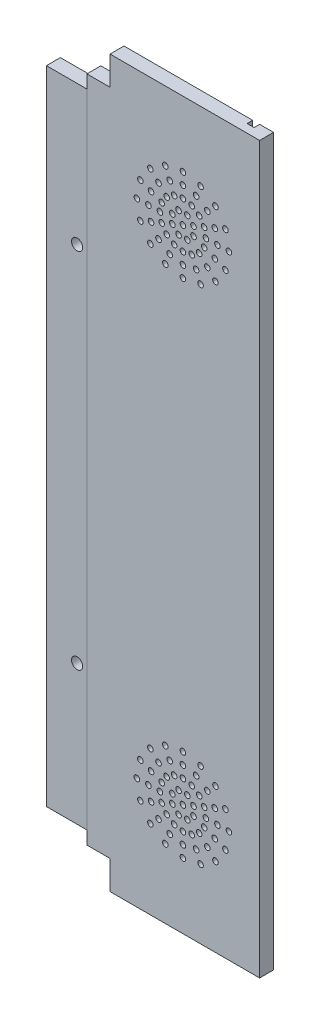
from build123d import *

# Parameters (mm, degrees)
CROQUIS1_W              = 67.920898
CROQUIS1_H              = 260
SALIENTE_EXTRUIR1_DEPTH = 5
CROQUIS3_W              = 2.5
CROQUIS3_H              = 260
CORTAR_EXTRUIR2_DEPTH   = 2
CORTAR_EXTRUIR3_REACH   = 7
CROQUIS5_R              = 1
CORTAR_EXTRUIR4_DEPTH   = 5
CROQUIS6_W              = 14.5
CROQUIS6_H              = 230
CROQUIS6_R              = 2
SALIENTE_EXTRUIR2_DEPTH = 5


with BuildPart() as part:
    # Croquis1 → Saliente-Extruir1 (new body)
    with BuildSketch(Plane.XY):
        with Locations((-1.84343465, -4.813673922)):
            Rectangle(CROQUIS1_W, CROQUIS1_H)
    extrude(amount=SALIENTE_EXTRUIR1_DEPTH)

    # Croquis3 → Cortar-Extruir2 (cut)
    with BuildSketch(Plane(origin=(0, 0, 0), x_dir=(-1, 0, 0), z_dir=(0, 0, -1))):
        with Locations((-25.86701435, -4.813673922)):
            Rectangle(CROQUIS3_W, CROQUIS3_H)
    extrude(amount=-CORTAR_EXTRUIR2_DEPTH, mode=Mode.SUBTRACT)

    # Croquis4 → Cortar-Extruir3 (cut, up to next)
    with BuildSketch(Plane(origin=(0, 0, 0), x_dir=(-1, 0, 0), z_dir=(0, 0, -1)), mode=Mode.PRIVATE) as cortar_extruir3_sk1:
        Polygon((35.80388365, 125.186326078), (29.80388365, 125.186326078), (21.50388365, 125.186326078), (21.50388365, 114.886326078), (29.80388365, 114.886326078), (29.80388365, -124.513673922), (21.50388365, -124.513673922), (21.50388365, -134.813673922), (29.80388365, -134.813673922), (35.80388365, -134.813673922), align=None)
    cortar_extruir3_tool1 = extrude(cortar_extruir3_sk1.sketch, amount=-CORTAR_EXTRUIR3_REACH, mode=Mode.PRIVATE) & part.part
    add(cortar_extruir3_tool1.solids().sort_by_distance((-32.097632, -4.813674, 0))[0], mode=Mode.SUBTRACT)

    # Croquis5 → Cortar-Extruir4 (cut)
    with BuildSketch(Plane(origin=(0, 0, 0), x_dir=(-1, 0, 0), z_dir=(0, 0, -1))):
        with Locations((-4.61701435, 101.686326078)):
            Circle(CROQUIS5_R)
        with Locations((-4.61701435, 97.556326078)):
            Circle(CROQUIS5_R)
        with Locations((-4.61701435, 93.426326078)):
            Circle(CROQUIS5_R)
        with Locations((-4.61701435, 85.166326078)):
            Circle(CROQUIS5_R)
        with Locations((-3.044185443, 88.983470956)):
            Circle(CROQUIS5_R)
        with Locations((-1.463702867, 92.799093426)):
            Circle(CROQUIS5_R)
        with Locations((0.116779709, 96.614715895)):
            Circle(CROQUIS5_R)
        with Locations((1.697262284, 100.430338364)):
            Circle(CROQUIS5_R)
        with Locations((1.209545527, 91.012885955)):
            Circle(CROQUIS5_R)
        with Locations((4.129896534, 93.933236961)):
            Circle(CROQUIS5_R)
        with Locations((7.05024754, 96.853587967)):
            Circle(CROQUIS5_R)
        with Locations((-0.819869471, 86.759154985)):
            Circle(CROQUIS5_R)
        with Locations((2.995752998, 88.33963756)):
            Circle(CROQUIS5_R)
        with Locations((6.811375467, 89.920120136)):
            Circle(CROQUIS5_R)
        with Locations((10.626997937, 91.500602712)):
            Circle(CROQUIS5_R)
        with Locations((3.62298565, 85.186326078)):
            Circle(CROQUIS5_R)
        with Locations((7.75298565, 85.186326078)):
            Circle(CROQUIS5_R)
        with Locations((11.88298565, 85.186326078)):
            Circle(CROQUIS5_R)
        with Locations((-0.819869471, 83.613497171)):
            Circle(CROQUIS5_R)
        with Locations((2.995752998, 82.033014595)):
            Circle(CROQUIS5_R)
        with Locations((6.811375467, 80.452532019)):
            Circle(CROQUIS5_R)
        with Locations((10.626997937, 78.872049444)):
            Circle(CROQUIS5_R)
        with Locations((1.209545527, 79.359766201)):
            Circle(CROQUIS5_R)
        with Locations((4.129896534, 76.439415194)):
            Circle(CROQUIS5_R)
        with Locations((7.05024754, 73.519064188)):
            Circle(CROQUIS5_R)
        with Locations((-3.044185443, 81.389181199)):
            Circle(CROQUIS5_R)
        with Locations((-1.463702867, 77.57355873)):
            Circle(CROQUIS5_R)
        with Locations((0.116779709, 73.75793626)):
            Circle(CROQUIS5_R)
        with Locations((1.697262284, 69.942313791)):
            Circle(CROQUIS5_R)
        with Locations((-4.61701435, 76.946326078)):
            Circle(CROQUIS5_R)
        with Locations((-4.61701435, 72.816326078)):
            Circle(CROQUIS5_R)
        with Locations((-4.61701435, 68.686326078)):
            Circle(CROQUIS5_R)
        with Locations((-6.189843257, 81.389181199)):
            Circle(CROQUIS5_R)
        with Locations((-7.770325832, 77.57355873)):
            Circle(CROQUIS5_R)
        with Locations((-9.350808408, 73.75793626)):
            Circle(CROQUIS5_R)
        with Locations((-10.931290984, 69.942313791)):
            Circle(CROQUIS5_R)
        with Locations((-10.443574227, 79.359766201)):
            Circle(CROQUIS5_R)
        with Locations((-13.363925233, 76.439415194)):
            Circle(CROQUIS5_R)
        with Locations((-16.284276239, 73.519064188)):
            Circle(CROQUIS5_R)
        with Locations((-8.414159228, 83.613497171)):
            Circle(CROQUIS5_R)
        with Locations((-12.229781698, 82.033014595)):
            Circle(CROQUIS5_R)
        with Locations((-16.045404167, 80.452532019)):
            Circle(CROQUIS5_R)
        with Locations((-19.861026636, 78.872049444)):
            Circle(CROQUIS5_R)
        with Locations((-12.85701435, 85.186326078)):
            Circle(CROQUIS5_R)
        with Locations((-16.98701435, 85.186326078)):
            Circle(CROQUIS5_R)
        with Locations((-21.11701435, 85.186326078)):
            Circle(CROQUIS5_R)
        with Locations((-8.414159228, 86.759154985)):
            Circle(CROQUIS5_R)
        with Locations((-12.229781698, 88.33963756)):
            Circle(CROQUIS5_R)
        with Locations((-16.045404167, 89.920120136)):
            Circle(CROQUIS5_R)
        with Locations((-19.861026636, 91.500602712)):
            Circle(CROQUIS5_R)
        with Locations((-10.443574227, 91.012885955)):
            Circle(CROQUIS5_R)
        with Locations((-13.363925233, 93.933236961)):
            Circle(CROQUIS5_R)
        with Locations((-16.284276239, 96.853587967)):
            Circle(CROQUIS5_R)
        with Locations((-6.189843257, 88.983470956)):
            Circle(CROQUIS5_R)
        with Locations((-7.770325832, 92.799093426)):
            Circle(CROQUIS5_R)
        with Locations((-9.350808408, 96.614715895)):
            Circle(CROQUIS5_R)
        with Locations((-10.931290984, 100.430338364)):
            Circle(CROQUIS5_R)
        with Locations((-10.931290984, -110.057686209)):
            Circle(CROQUIS5_R)
        with Locations((-9.350808408, -106.24206374)):
            Circle(CROQUIS5_R)
        with Locations((-7.770325832, -102.42644127)):
            Circle(CROQUIS5_R)
        with Locations((-6.189843257, -98.610818801)):
            Circle(CROQUIS5_R)
        with Locations((-16.284276239, -106.480935812)):
            Circle(CROQUIS5_R)
        with Locations((-13.363925233, -103.560584806)):
            Circle(CROQUIS5_R)
        with Locations((-10.443574227, -100.640233799)):
            Circle(CROQUIS5_R)
        with Locations((-19.861026636, -101.127950556)):
            Circle(CROQUIS5_R)
        with Locations((-16.045404167, -99.547467981)):
            Circle(CROQUIS5_R)
        with Locations((-12.229781698, -97.966985405)):
            Circle(CROQUIS5_R)
        with Locations((-8.414159228, -96.386502829)):
            Circle(CROQUIS5_R)
        with Locations((-21.11701435, -94.813673922)):
            Circle(CROQUIS5_R)
        with Locations((-16.98701435, -94.813673922)):
            Circle(CROQUIS5_R)
        with Locations((-12.85701435, -94.813673922)):
            Circle(CROQUIS5_R)
        with Locations((-19.861026636, -88.499397288)):
            Circle(CROQUIS5_R)
        with Locations((-16.045404167, -90.079879864)):
            Circle(CROQUIS5_R)
        with Locations((-12.229781698, -91.66036244)):
            Circle(CROQUIS5_R)
        with Locations((-8.414159228, -93.240845015)):
            Circle(CROQUIS5_R)
        with Locations((-16.284276239, -83.146412033)):
            Circle(CROQUIS5_R)
        with Locations((-13.363925233, -86.066763039)):
            Circle(CROQUIS5_R)
        with Locations((-10.443574227, -88.987114045)):
            Circle(CROQUIS5_R)
        with Locations((-10.931290984, -79.569661636)):
            Circle(CROQUIS5_R)
        with Locations((-9.350808408, -83.385284105)):
            Circle(CROQUIS5_R)
        with Locations((-7.770325832, -87.200906574)):
            Circle(CROQUIS5_R)
        with Locations((-6.189843257, -91.016529044)):
            Circle(CROQUIS5_R)
        with Locations((-4.61701435, -78.313673922)):
            Circle(CROQUIS5_R)
        with Locations((-4.61701435, -82.443673922)):
            Circle(CROQUIS5_R)
        with Locations((-4.61701435, -86.573673922)):
            Circle(CROQUIS5_R)
        with Locations((1.697262284, -79.569661636)):
            Circle(CROQUIS5_R)
        with Locations((0.116779709, -83.385284105)):
            Circle(CROQUIS5_R)
        with Locations((-1.463702867, -87.200906574)):
            Circle(CROQUIS5_R)
        with Locations((-3.044185443, -91.016529044)):
            Circle(CROQUIS5_R)
        with Locations((7.05024754, -83.146412033)):
            Circle(CROQUIS5_R)
        with Locations((4.129896534, -86.066763039)):
            Circle(CROQUIS5_R)
        with Locations((1.209545527, -88.987114045)):
            Circle(CROQUIS5_R)
        with Locations((10.626997937, -88.499397288)):
            Circle(CROQUIS5_R)
        with Locations((6.811375467, -90.079879864)):
            Circle(CROQUIS5_R)
        with Locations((2.995752998, -91.66036244)):
            Circle(CROQUIS5_R)
        with Locations((-0.819869471, -93.240845015)):
            Circle(CROQUIS5_R)
        with Locations((11.88298565, -94.813673922)):
            Circle(CROQUIS5_R)
        with Locations((7.75298565, -94.813673922)):
            Circle(CROQUIS5_R)
        with Locations((3.62298565, -94.813673922)):
            Circle(CROQUIS5_R)
        with Locations((10.626997937, -101.127950556)):
            Circle(CROQUIS5_R)
        with Locations((6.811375467, -99.547467981)):
            Circle(CROQUIS5_R)
        with Locations((2.995752998, -97.966985405)):
            Circle(CROQUIS5_R)
        with Locations((-0.819869471, -96.386502829)):
            Circle(CROQUIS5_R)
        with Locations((7.05024754, -106.480935812)):
            Circle(CROQUIS5_R)
        with Locations((4.129896534, -103.560584806)):
            Circle(CROQUIS5_R)
        with Locations((1.209545527, -100.640233799)):
            Circle(CROQUIS5_R)
        with Locations((1.697262284, -110.057686209)):
            Circle(CROQUIS5_R)
        with Locations((0.116779709, -106.24206374)):
            Circle(CROQUIS5_R)
        with Locations((-1.463702867, -102.42644127)):
            Circle(CROQUIS5_R)
        with Locations((-3.044185443, -98.610818801)):
            Circle(CROQUIS5_R)
        with Locations((-4.61701435, -94.793673922)):
            Circle(CROQUIS5_R)
        with Locations((-4.61701435, -103.053673922)):
            Circle(CROQUIS5_R)
        with Locations((-4.61701435, -107.183673922)):
            Circle(CROQUIS5_R)
        with Locations((-4.61701435, -111.313673922)):
            Circle(CROQUIS5_R)
    extrude(amount=-CORTAR_EXTRUIR4_DEPTH, mode=Mode.SUBTRACT)


with BuildPart() as body_2:
    # Croquis6 → Saliente-Extruir2 (new body)
    with BuildSketch(Plane(origin=(0, 0, 0), x_dir=(-1, 0, 0), z_dir=(0, 0, -1))):
        with Locations((37.06388365, -4.813673922)):
            Rectangle(CROQUIS6_W, CROQUIS6_H)
        with Locations((33.31388365, 60.186326078)):
            Circle(CROQUIS6_R, mode=Mode.SUBTRACT)
        with Locations((33.31388365, -69.813673922)):
            Circle(CROQUIS6_R, mode=Mode.SUBTRACT)
    extrude(amount=-SALIENTE_EXTRUIR2_DEPTH)


solid = Compound([part.part, body_2.part])
